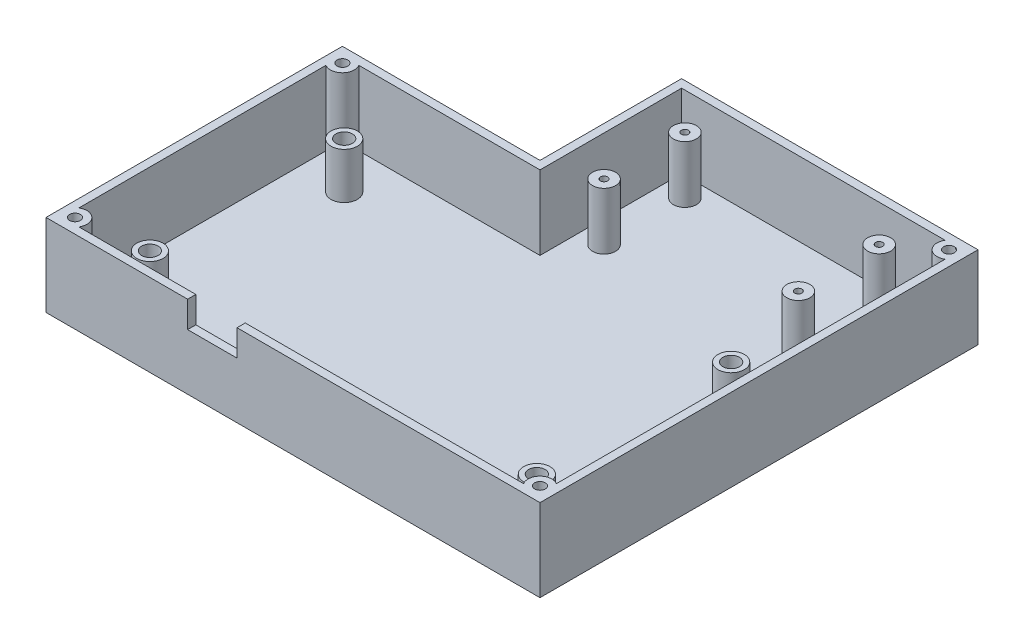
from build123d import *

# Parameters (mm, degrees)
SKETCH1_W           = 190.5
SKETCH1_H           = 114.3
BOSS_EXTRUDE1_DEPTH = 31.75
SKETCH2_W           = 184.15
SKETCH2_H           = 107.95
CUT_EXTRUDE1_DEPTH  = 28.575
SKETCH3_R           = 5.08
BOSS_EXTRUDE2_DEPTH = 17.78
SKETCH4_R           = 3.175
CUT_EXTRUDE2_DEPTH  = 12.7
SKETCH5_W           = 19.05
SKETCH5_H           = 25.4
CUT_EXTRUDE3_DEPTH  = 12.7
SKETCH6_W           = 114.3
SKETCH6_H           = 54.61
BOSS_EXTRUDE3_DEPTH = 31.75
SKETCH7_W           = 107.95
SKETCH7_H           = 58.521622115
CUT_EXTRUDE4_DEPTH  = 28.575
SKETCH8_R           = 4.445
BOSS_EXTRUDE4_DEPTH = 21.971
SKETCH10_R          = 1.3716
CUT_EXTRUDE5_DEPTH  = 12.7
SKETCH11_R          = 4.604419826
BOSS_EXTRUDE5_DEPTH = 28.575
SKETCH12_R          = 2.064419826
CUT_EXTRUDE6_DEPTH  = 28.575


with BuildPart() as part:
    # Sketch1 → Boss-Extrude1 (new body)
    with BuildSketch(Plane(origin=(0, 0, 0), x_dir=(1, 0, 0), z_dir=(0, 1, 0))):
        with Locations((95.25, 57.15)):
            Rectangle(SKETCH1_W, SKETCH1_H)
    extrude(amount=BOSS_EXTRUDE1_DEPTH)

    # Sketch2 → Cut-Extrude1 (cut)
    with BuildSketch(Plane(origin=(0, 31.75, 0), x_dir=(1, 0, 0), z_dir=(0, 1, 0))):
        with Locations((95.25, 57.15)):
            Rectangle(SKETCH2_W, SKETCH2_H)
    extrude(amount=-CUT_EXTRUDE1_DEPTH, mode=Mode.SUBTRACT)

    # Sketch3 → Boss-Extrude2 (add)
    with BuildSketch(Plane(origin=(0, 3.175, 0), x_dir=(1, 0, 0), z_dir=(0, 1, 0))):
        with Locations((20.378923162, 94.615)):
            Circle(SKETCH3_R)
        with Locations((169.603923162, 94.615)):
            Circle(SKETCH3_R)
        with Locations((169.603923162, 19.685)):
            Circle(SKETCH3_R)
        with Locations((20.378923162, 19.685)):
            Circle(SKETCH3_R)
    extrude(amount=BOSS_EXTRUDE2_DEPTH)

    # Sketch4 → Cut-Extrude2 (cut)
    with BuildSketch(Plane(origin=(0, 20.955, 0), x_dir=(1, 0, 0), z_dir=(0, 1, 0))):
        with Locations((20.378923162, 94.615)):
            Circle(SKETCH4_R)
        with Locations((169.603923162, 94.615)):
            Circle(SKETCH4_R)
        with Locations((20.378923162, 19.685)):
            Circle(SKETCH4_R)
        with Locations((169.603923162, 19.685)):
            Circle(SKETCH4_R)
    extrude(amount=-CUT_EXTRUDE2_DEPTH, mode=Mode.SUBTRACT)

    # Sketch5 → Cut-Extrude3 (cut)
    with BuildSketch(Plane.XY):
        with Locations((64.135, 34.29)):
            Rectangle(SKETCH5_W, SKETCH5_H)
    extrude(amount=-CUT_EXTRUDE3_DEPTH, mode=Mode.SUBTRACT)

    # Sketch6 → Boss-Extrude3 (add)
    with BuildSketch(Plane.XZ):
        with Locations((133.35, -141.605)):
            Rectangle(SKETCH6_W, SKETCH6_H)
    extrude(amount=-BOSS_EXTRUDE3_DEPTH)

    # Sketch7 → Cut-Extrude4 (cut)
    with BuildSketch(Plane(origin=(0, 31.75, 0), x_dir=(1, 0, 0), z_dir=(0, 1, 0))):
        with Locations((133.35, 136.474188943)):
            Rectangle(SKETCH7_W, SKETCH7_H)
    extrude(amount=-CUT_EXTRUDE4_DEPTH, mode=Mode.SUBTRACT)

    # Sketch8 → Boss-Extrude4 (add)
    with BuildSketch(Plane(origin=(0, 3.175, 0), x_dir=(1, 0, 0), z_dir=(0, 1, 0))):
        with Locations((88.138, 127.0635)):
            Circle(SKETCH8_R)
        with Locations((163.068, 127.0635)):
            Circle(SKETCH8_R)
        with Locations((163.068, 158.242)):
            Circle(SKETCH8_R)
        with Locations((88.138, 158.242)):
            Circle(SKETCH8_R)
    extrude(amount=BOSS_EXTRUDE4_DEPTH)

    # Sketch10 → Cut-Extrude5 (cut)
    with BuildSketch(Plane(origin=(0, 25.146, 0), x_dir=(1, 0, 0), z_dir=(0, 1, 0))):
        with Locations((163.068, 127.0635)):
            Circle(SKETCH10_R)
        with Locations((88.138, 127.0635)):
            Circle(SKETCH10_R)
        with Locations((88.138, 158.242)):
            Circle(SKETCH10_R)
        with Locations((163.068, 158.242)):
            Circle(SKETCH10_R)
    extrude(amount=-CUT_EXTRUDE5_DEPTH, mode=Mode.SUBTRACT)

    # Sketch11 → Boss-Extrude5 (add)
    with BuildSketch(Plane(origin=(0, 3.175, 0), x_dir=(1, 0, 0), z_dir=(0, 1, 0))):
        with Locations((184.912, 5.588)):
            Circle(SKETCH11_R)
        with Locations((5.588, 5.588)):
            Circle(SKETCH11_R)
        with Locations((5.588, 108.712)):
            Circle(SKETCH11_R)
        with Locations((184.912, 163.322)):
            Circle(SKETCH11_R)
    extrude(amount=BOSS_EXTRUDE5_DEPTH)

    # Sketch12 → Cut-Extrude6 (cut)
    with BuildSketch(Plane(origin=(0, 31.75, 0), x_dir=(1, 0, 0), z_dir=(0, 1, 0))):
        with Locations((184.912, 5.588)):
            Circle(SKETCH12_R)
        with Locations((5.588, 5.588)):
            Circle(SKETCH12_R)
        with Locations((5.588, 108.712)):
            Circle(SKETCH12_R)
        with Locations((184.912, 163.322)):
            Circle(SKETCH12_R)
    extrude(amount=-CUT_EXTRUDE6_DEPTH, mode=Mode.SUBTRACT)


solid = part.part
